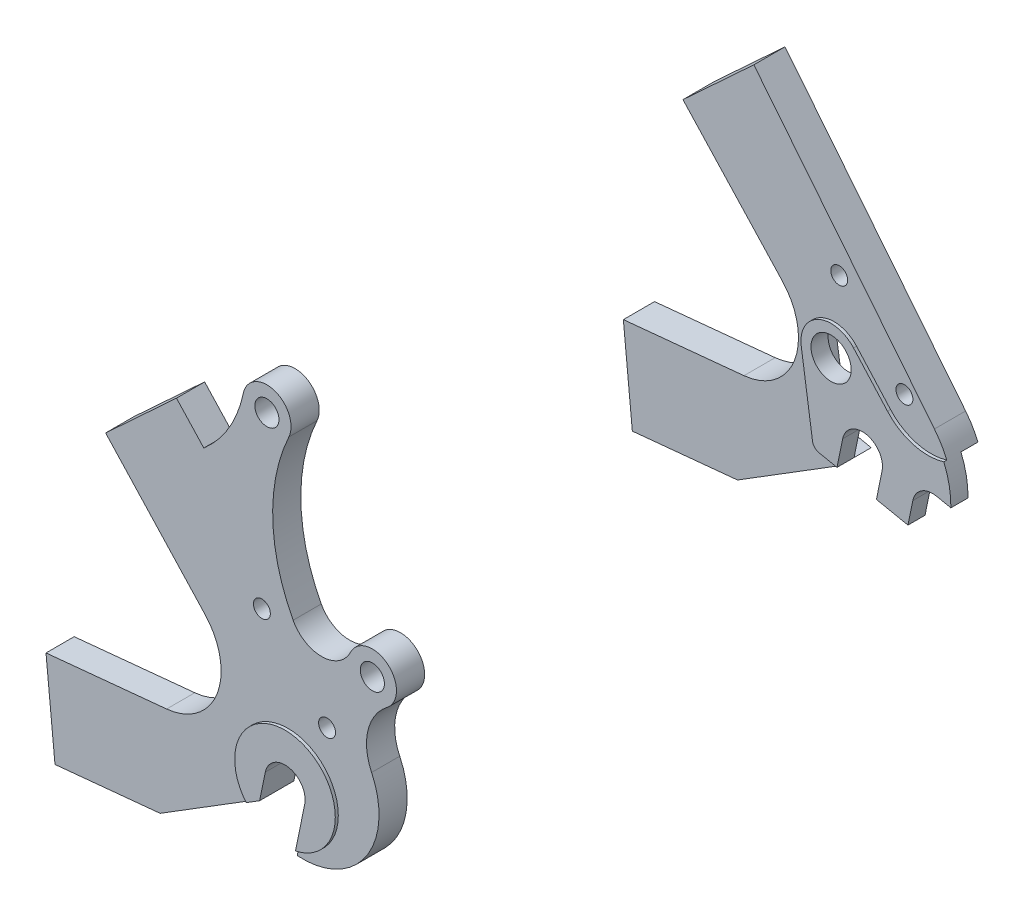
from build123d import *

# Parameters (mm, degrees)
EXTRUSION8_DEPTH             = 3.5
ESQUISSE25_R                 = 2.1
ESQUISSE25_R_2               = 3
ENL_V_MAT_EXTRU_7_DEPTH      = 4.5
ENL_V_MAT_EXTRU_7_DEPTH_BACK = 4.5
EXTRUSION9_DEPTH             = 4.25
EXTRUSION10_DEPTH            = 3.5
EXTRUSION10_DEPTH_BACK       = 4.25
ENL_V_MAT_EXTRU_8_DEPTH      = 5.25
EXTRUSION11_DEPTH            = 4.25
ENL_V_START                  = -4.25
ESQUISSE29_R                 = 5
ESQUISSE29_R_2               = 2.1
ENL_V_MAT_EXTRU_9_DEPTH      = 8.5


with BuildPart() as part:
    # Esquisse24 → Extrusion8 (new body, symmetric)
    with BuildSketch(Plane.XY.offset(71.75)):
        with BuildLine():
            Line((461.995766883, 50.594183039), (459.390681209, 37.857875543))
            ThreePointArc((459.390681209, 37.857875543), (476.419566024, 46.116324353), (477.86706581, 64.986661902))
            ThreePointArc((477.86706581, 64.986661902), (476.963568853, 73.623976526), (481.700303248, 80.902908999))
            ThreePointArc((481.700303248, 80.902908999), (481.840076705, 90.321321022), (472.646856003, 88.269318395))
            ThreePointArc((472.646856003, 88.269318395), (465.58603542, 83.740072967), (458.362772931, 88.005483904))
            ThreePointArc((458.362772931, 88.005483904), (453.294594284, 107.335459009), (457.298805353, 126.913524952))
            ThreePointArc((457.298805353, 126.913524952), (453.719385793, 135.119639281), (445.971344073, 130.634061698))
            ThreePointArc((445.971344073, 130.634061698), (442.447554772, 121.492162619), (436.166159284, 113.97315467))
            Line((436.166159284, 113.97315467), (429.374657578, 121.313148169))
            Line((429.374657578, 121.313148169), (411.758673179, 105.013544073))
            Line((411.758673179, 105.013544073), (436.482729278, 78.292736383))
            ThreePointArc((436.482729278, 78.292736383), (439.492589592, 62.772211826), (426.92820657, 53.176263674))
            Line((426.92820657, 53.176263674), (396.943666221, 50.253034947))
            Line((396.943666221, 50.253034947), (399.175383117, 27.361564053))
            Line((399.175383117, 27.361564053), (425.312556128, 29.909708333))
            Line((425.312556128, 29.909708333), (450.795868831, 45.740083367))
            Line((450.795868831, 45.740083367), (452.19860727, 52.598095095))
            ThreePointArc((452.19860727, 52.598095095), (458.099143105, 56.494718873), (461.995766883, 50.594183039))
        make_face()
    extrude(amount=EXTRUSION8_DEPTH, both=True)

    # Esquisse25 → Enlèv. mat.-Extru.7 (cut, two sides)
    with BuildSketch(Plane.XY.offset(71.75)) as enl_v_mat_extru_7_sk:
        with Locations((466.801883269, 69.083816781)):
            Circle(ESQUISSE25_R)
        with Locations((451.847076239, 129.419248335)):
            Circle(ESQUISSE25_R_2)
        with Locations((450.598194981, 86.596139067)):
            Circle(ESQUISSE25_R)
        with Locations((478.053275681, 85.667275685)):
            Circle(ESQUISSE25_R_2)
    extrude(amount=ENL_V_MAT_EXTRU_7_DEPTH, mode=Mode.SUBTRACT)
    extrude(enl_v_mat_extru_7_sk.sketch, amount=-ENL_V_MAT_EXTRU_7_DEPTH_BACK, mode=Mode.SUBTRACT)

    # Esquisse26 → Extrusion9 (add, symmetric)
    with BuildSketch(Plane.XY.offset(71.75)):
        with BuildLine():
            Line((461.995766883, 50.594183039), (459.699997211, 39.370126659))
            ThreePointArc((459.699997211, 39.370126659), (461.22355789, 63.395421414), (447.442283114, 43.65681734))
            Line((447.442283114, 43.65681734), (450.795868831, 45.740083367))
            Line((450.795868831, 45.740083367), (452.19860727, 52.598095095))
            ThreePointArc((452.19860727, 52.598095095), (458.099143105, 56.494718873), (461.995766883, 50.594183039))
        make_face()
    extrude(amount=EXTRUSION9_DEPTH, both=True)


with BuildPart() as body_2:
    # Esquisse27 → Extrusion10 (new body, two sides)
    with BuildSketch(Plane.XY.offset(-71.75)) as extrusion10_sk:
        with BuildLine():
            Line((429.374657578, 121.313148169), (474.257936186, 65.362354597))
            ThreePointArc((474.257936186, 65.362354597), (477.920241971, 58.695461914), (479.093248701, 51.179878309))
            Line((479.093248701, 51.179878309), (475.533639201, 51.90796121))
            ThreePointArc((475.533639201, 51.90796121), (471.776354076, 51.181690305), (469.633103367, 48.011337432))
            Line((469.633103367, 48.011337432), (468.430756133, 42.133041665))
            Line((468.430756133, 42.133041665), (460.593028443, 43.73617131))
            Line((460.593028443, 43.73617131), (461.995766883, 50.594183039))
            ThreePointArc((461.995766883, 50.594183039), (458.099143105, 56.494718873), (452.19860727, 52.598095095))
            Line((452.19860727, 52.598095095), (450.795868831, 45.740083367))
            Line((450.795868831, 45.740083367), (425.312556128, 29.909708333))
            Line((425.312556128, 29.909708333), (399.175383117, 27.361564053))
            Line((399.175383117, 27.361564053), (396.943666221, 50.253034947))
            Line((396.943666221, 50.253034947), (426.92820657, 53.176263674))
            ThreePointArc((426.92820657, 53.176263674), (439.492589592, 62.772211826), (436.482729278, 78.292736383))
            Line((436.482729278, 78.292736383), (411.758673179, 105.013544073))
            Line((411.758673179, 105.013544073), (429.374657578, 121.313148169))
        make_face()
    extrude(amount=EXTRUSION10_DEPTH)
    extrude(extrusion10_sk.sketch, amount=-EXTRUSION10_DEPTH_BACK)

    # Esquisse31 → Enlèv. mat.-Extru.8 (cut, through all)
    with BuildSketch(Plane.XY.offset(-71.75)):
        with BuildLine():
            Line((444.713406132, 48.32966438), (441.906110824, 67.404128849))
            ThreePointArc((441.906110824, 67.404128849), (446.1394526, 75.285494755), (454.907130769, 73.506469556))
            Line((454.907130769, 73.506469556), (463.346068037, 64.106351495))
            ThreePointArc((463.346068037, 64.106351495), (469.774472357, 60.118521705), (477.338724598, 60.214732849))
            ThreePointArc((477.338724598, 60.214732849), (478.693734128, 55.790081778), (479.093248701, 51.179878309))
            Line((479.093248701, 51.179878309), (475.533639201, 51.90796121))
            ThreePointArc((475.533639201, 51.90796121), (471.776354076, 51.181690305), (469.633103367, 48.011337432))
            Line((469.633103367, 48.011337432), (468.430756133, 42.133041665))
            Line((468.430756133, 42.133041665), (446.291308724, 46.661446564))
            ThreePointArc((446.291308724, 46.661446564), (445.239092868, 47.246543726), (444.713406132, 48.32966438))
        make_face()
    extrude(amount=-ENL_V_MAT_EXTRU_8_DEPTH, mode=Mode.SUBTRACT)

    # Esquisse32 → Extrusion11 (add)
    with BuildSketch(Plane.XY.offset(-71.75)):
        with BuildLine():
            Line((446.291308724, 46.661446564), (450.795868831, 45.740083367))
            Line((450.795868831, 45.740083367), (452.19860727, 52.598095095))
            ThreePointArc((452.19860727, 52.598095095), (458.099143105, 56.494718873), (461.995766883, 50.594183039))
            Line((461.995766883, 50.594183039), (460.593028443, 43.73617131))
            Line((460.593028443, 43.73617131), (468.430756133, 42.133041665))
            Line((468.430756133, 42.133041665), (469.633103367, 48.011337432))
            ThreePointArc((469.633103367, 48.011337432), (471.776354076, 51.181690305), (475.533639201, 51.90796121))
            Line((475.533639201, 51.90796121), (479.093248701, 51.179878309))
            ThreePointArc((479.093248701, 51.179878309), (478.693734128, 55.790081778), (477.338724598, 60.214732849))
            ThreePointArc((477.338724598, 60.214732849), (469.774472357, 60.118521705), (463.346068037, 64.106351495))
            Line((463.346068037, 64.106351495), (454.907130769, 73.506469556))
            ThreePointArc((454.907130769, 73.506469556), (446.1394526, 75.285494755), (441.906110824, 67.404128849))
            Line((441.906110824, 67.404128849), (444.713406132, 48.32966438))
            ThreePointArc((444.713406132, 48.32966438), (445.239092868, 47.246543726), (446.291308724, 46.661446564))
        make_face()
    extrude(amount=EXTRUSION11_DEPTH)

    # Esquisse29 → Enlèv. mat.-Extru.9 (cut)
    with BuildSketch(Plane.XY.offset(-71.75).offset(ENL_V_START)):
        with Locations((449.326179588, 68.496181748)):
            Circle(ESQUISSE29_R)
        with Locations(Location((466.801883269, 69.083816781, 0), (0, 0, 180))):  # turned: the seam where the file's is
            Circle(ESQUISSE29_R_2)
        with Locations(Location((450.598194981, 86.596139067, 0), (0, 0, 180))):  # turned: the seam where the file's is
            Circle(ESQUISSE29_R_2)
    extrude(amount=ENL_V_MAT_EXTRU_9_DEPTH, mode=Mode.SUBTRACT)


solid = Compound([part.part, body_2.part])
